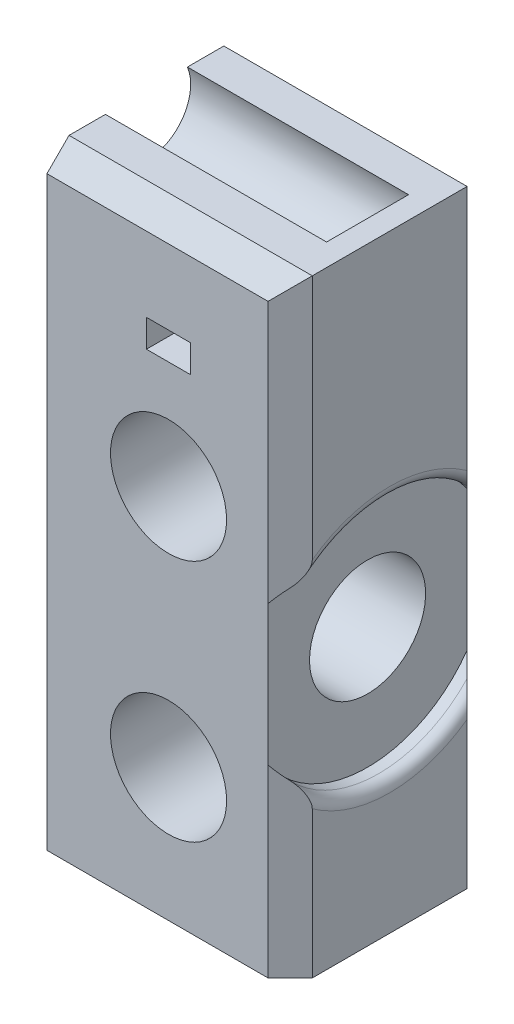
from build123d import *

# Parameters (mm, degrees)
SKETCH1_W           = 22
SKETCH1_H           = 55
SKETCH1_R           = 5.25
SKETCH1_W_2         = 4
SKETCH1_H_2         = 2.5
BOSS_EXTRUDE1_DEPTH = 18
SKETCH2_R           = 5.25
CUT_EXTRUDE1_DEPTH  = 23
SKETCH3_R           = 4
CUT_EXTRUDE2_DEPTH  = 20
CHAMFER1_SIZE       = 2
SKETCH4_R           = 11
CUT_EXTRUDE3_DEPTH  = 2
FILLET1_R           = 1
CHAMFER2_SIZE       = 2


with BuildPart() as part:
    # Sketch1 → Boss-Extrude1 (new body)
    with BuildSketch(Plane.XY):
        with Locations((11, 27.5)):
            Rectangle(SKETCH1_W, SKETCH1_H)
        with Locations((11, 12)):
            Circle(SKETCH1_R, mode=Mode.SUBTRACT)
        with Locations((11, 34)):
            Circle(SKETCH1_R, mode=Mode.SUBTRACT)
        with Locations((11, 45)):
            Rectangle(SKETCH1_W_2, SKETCH1_H_2, mode=Mode.SUBTRACT)
    extrude(amount=-BOSS_EXTRUDE1_DEPTH)

    # Sketch2 → Cut-Extrude1 (cut, through all)
    with BuildSketch(Plane.ZY):
        with Locations((-9, 23)):
            Circle(SKETCH2_R)
    extrude(amount=-CUT_EXTRUDE1_DEPTH, mode=Mode.SUBTRACT)

    # Sketch3 → Cut-Extrude2 (cut)
    with BuildSketch(Plane(origin=(0, 0, 0), x_dir=(0, 0, -1), z_dir=(1, 0, 0))):
        with Locations((9, 53.5)):
            Circle(SKETCH3_R)
    extrude(amount=CUT_EXTRUDE2_DEPTH, mode=Mode.SUBTRACT)

    # Chamfer1
    chamfer1_edges = [part.edges().sort_by_distance(p)[0] for p in [
        (22, 27.5, 0),
        (22, 27.5, -18),
    ]]
    chamfer(chamfer1_edges, length=CHAMFER1_SIZE)

    # Sketch4 → Cut-Extrude3 (cut)
    with BuildSketch(Plane(origin=(22, 0, 0), x_dir=(0, 0, -1), z_dir=(1, 0, 0))):
        with Locations((9, 23)):
            Circle(SKETCH4_R)
    extrude(amount=-CUT_EXTRUDE3_DEPTH, mode=Mode.SUBTRACT)

    # Fillet1
    fillet1_edges = [part.edges().sort_by_distance(p)[0] for p in [
        (22, 34, -9),
        (22, 12, -9),
    ]]
    fillet(fillet1_edges, radius=FILLET1_R)

    # Chamfer2
    chamfer2_edges = [part.edges().sort_by_distance(p)[0] for p in [
        (10, 55, 0),
        (10, 55, -18),
    ]]
    chamfer(chamfer2_edges, length=CHAMFER2_SIZE)


solid = part.part
